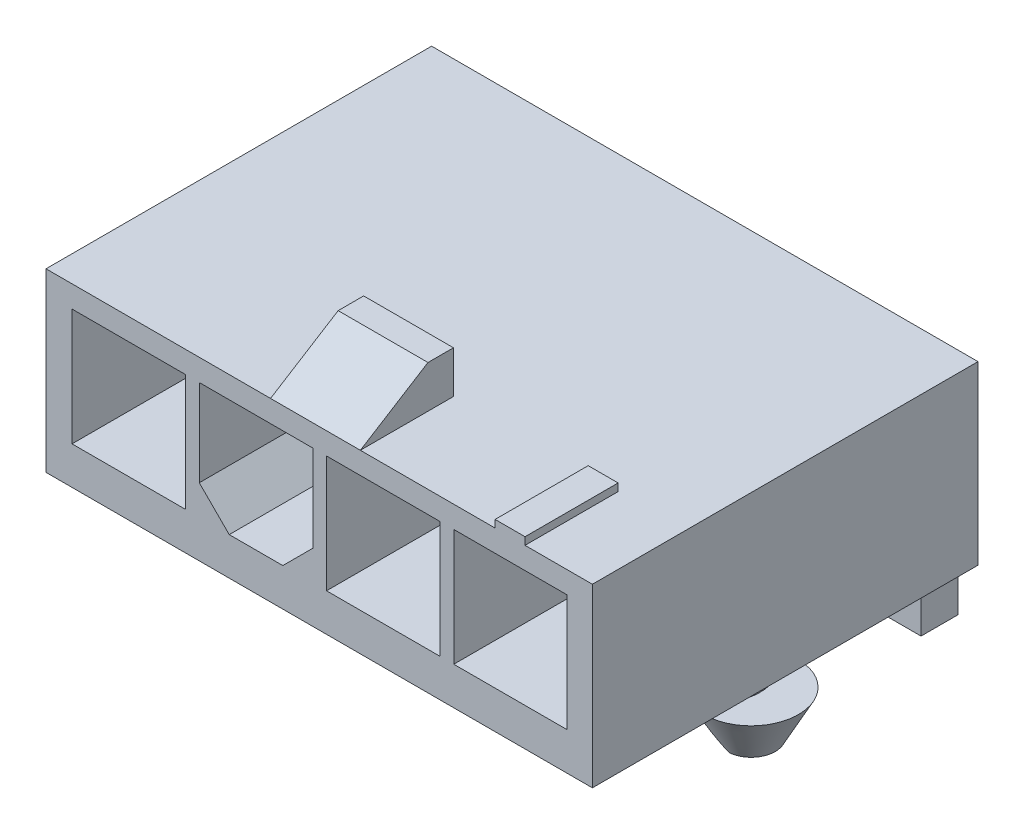
from build123d import *

# Parameters (mm, degrees)
SKETCH1_W                     = 18.25
SKETCH1_H                     = 12.88
BOSS_EXTRUDE1_DEPTH           = 5.89
SKETCH2_W                     = 3.79
SKETCH2_H                     = 3.9
CUT_EXTRUDE1_DEPTH            = 9
SKETCH3_W                     = 3
SKETCH3_H                     = 3.11
BOSS_EXTRUDE2_DEPTH           = 1.41
CUT_EXTRUDE2_DEPTH            = 3
SKETCH5_W                     = 1.23
SKETCH5_H                     = 1.23
CUT_EXTRUDE3_DEPTH            = 4
SKETCH8_W                     = 1.23
SKETCH8_H                     = 1.23
SKETCH9_W                     = 1
SKETCH9_H                     = 3.11
BOSS_EXTRUDE3_DEPTH           = 0.25
BOSS_EXTRUDE5_DEPTH           = 1.5875
BOSS_EXTRUDE6_DEPTH           = 1.46
BOSS_EXTRUDE6_DRAFT           = 28
BOSS_EXTRUDE6_PROFILE_2_DEPTH = 1.46
BOSS_EXTRUDE6_PROFILE_2_DRAFT = 28
BOSS_EXTRUDE6_PROFILE_3_DEPTH = 1.46
BOSS_EXTRUDE6_PROFILE_3_DRAFT = 28
BOSS_EXTRUDE6_PROFILE_4_DEPTH = 1.46
BOSS_EXTRUDE6_PROFILE_4_DRAFT = 28


with BuildPart() as part:
    # Sketch1 → Boss-Extrude1 (new body)
    with BuildSketch(Plane(origin=(0, 0, 0), x_dir=(1, 0, 0), z_dir=(0, 1, 0))):
        with Locations((9.125, 6.44)):
            Rectangle(SKETCH1_W, SKETCH1_H)
    extrude(amount=BOSS_EXTRUDE1_DEPTH)

    # Sketch2 → Cut-Extrude1 (cut)
    with BuildSketch(Plane.XY):
        with Locations((2.765, 3.21048567)):
            Rectangle(SKETCH2_W, SKETCH2_H)
        Polygon((5.12, 5.16048567), (8.91, 5.16048567), (8.91, 2.26048567), (7.91, 1.26048567), (6.12, 1.26048567), (5.12, 2.26048567), align=None)
        with Locations((11.265, 3.21048567)):
            Rectangle(SKETCH2_W, SKETCH2_H)
        with Locations((15.515, 3.21048567)):
            Rectangle(SKETCH2_W, SKETCH2_H)
    extrude(amount=-CUT_EXTRUDE1_DEPTH, mode=Mode.SUBTRACT)

    # Sketch3 → Boss-Extrude2 (add)
    with BuildSketch(Plane(origin=(0, 5.89, 0), x_dir=(1, 0, 0), z_dir=(0, 1, 0))):
        with Locations((9, 1.555)):
            Rectangle(SKETCH3_W, SKETCH3_H)
    extrude(amount=BOSS_EXTRUDE2_DEPTH)

    # Sketch4 → Cut-Extrude2 (cut)
    with BuildSketch(Plane.ZY.offset(-7.5)):
        Polygon((-2.258367839, 7.3), (0, 5.89), (0, 7.3), align=None)
    extrude(amount=-CUT_EXTRUDE2_DEPTH, mode=Mode.SUBTRACT)

    # Sketch5 → Cut-Extrude3 (cut)
    with BuildSketch(Plane(origin=(0, 0, -12.88), x_dir=(-1, 0, 0), z_dir=(0, 0, -1))):
        with Locations((-2.785, 2.645)):
            Rectangle(SKETCH5_W, SKETCH5_H)
        with Locations((-6.990239219, 2.642823938)):
            Rectangle(SKETCH5_W, SKETCH5_H)
        with Locations((-11.195478439, 2.640647876)):
            Rectangle(SKETCH5_W, SKETCH5_H)
        with Locations((-15.400717658, 2.638471814)):
            Rectangle(SKETCH5_W, SKETCH5_H)
    extrude(amount=-CUT_EXTRUDE3_DEPTH, mode=Mode.SUBTRACT)

    # Sweep2: sweep along a path in Sketch7
    with BuildLine(Plane.ZY) as sweep2_path:
        Line((-4.3, 2.72), (-12.700459496, 2.72))
        ThreePointArc((-12.700459496, 2.72), (-13.534520585, 2.374520585), (-13.88, 1.540459496))
        Line((-13.88, 1.540459496), (-13.88, -3.3375))
    # Sketch8 → Sweep2 (sweep)
    with BuildSketch(Plane.XZ.offset(3.3375)):
        with Locations((15.397064507, -13.830209109)):
            Rectangle(SKETCH8_W, SKETCH8_H)
        with Locations((11.191825288, -13.832385171)):
            Rectangle(SKETCH8_W, SKETCH8_H)
        with Locations((6.986586068, -13.834561233)):
            Rectangle(SKETCH8_W, SKETCH8_H)
        with Locations((2.781346849, -13.836737294)):
            Rectangle(SKETCH8_W, SKETCH8_H)
    sweep(path=sweep2_path.line)

    # Sketch9 → Boss-Extrude3 (add)
    with BuildSketch(Plane(origin=(0, 5.89, 0), x_dir=(1, 0, 0), z_dir=(0, 1, 0))):
        with Locations((15.5, 1.555)):
            Rectangle(SKETCH9_W, SKETCH9_H)
    extrude(amount=BOSS_EXTRUDE3_DEPTH)

    # Sketch10 → Boss-Extrude5 (add)
    with BuildSketch(Plane.XZ):
        with BuildLine():
            Line((2.55, -5.735786438), (2.55, -8.564213562))
            ThreePointArc((2.55, -8.564213562), (1.55, -7.15), (2.55, -5.735786438))
        make_face()
        with BuildLine():
            Line((3.55, -5.735786438), (3.55, -8.564213562))
            ThreePointArc((3.55, -8.564213562), (4.55, -7.15), (3.55, -5.735786438))
        make_face()
        with BuildLine():
            Line((14.7, -5.735786438), (14.7, -8.564213562))
            ThreePointArc((14.7, -8.564213562), (13.7, -7.15), (14.7, -5.735786438))
        make_face()
        with BuildLine():
            Line((15.7, -5.735786438), (15.7, -8.564213562))
            ThreePointArc((15.7, -8.564213562), (16.7, -7.15), (15.7, -5.735786438))
        make_face()
    extrude(amount=BOSS_EXTRUDE5_DEPTH)


with BuildPart() as boss_extrude6_tool:
    # Sketch12 → Boss-Extrude6 (with draft: the straight prism first)
    with BuildSketch(Plane.XZ.offset(1.5875)):
        with BuildLine():
            ThreePointArc((2.55, -5.735786438), (0.266263579, -7.15), (2.55, -8.564213562))
            Line((2.55, -8.564213562), (2.55, -5.735786438))
        make_face()
    extrude(amount=BOSS_EXTRUDE6_DEPTH)
    # Boss-Extrude6: the draft: its side faces are tilted about the plane it starts from
    boss_extrude6_sides = [boss_extrude6_tool.faces().sort_by_distance(p)[0] for p in [
        (2.55, -2.3175, -7.15),
        (0.266263579, -2.3175, -7.15),
    ]]
    draft(boss_extrude6_sides, Plane.XZ.offset(1.5875), BOSS_EXTRUDE6_DRAFT)


with BuildPart() as part_1:
    add(part.part)

    # Boss-Extrude6: add boss_extrude6_tool
    add(boss_extrude6_tool.part)


with BuildPart() as boss_extrude6_profile_2_tool:
    # Sketch12 → Boss-Extrude6 profile 2 (with draft: the straight prism first)
    with BuildSketch(Plane.XZ.offset(1.5875)):
        with BuildLine():
            Line((3.55, -5.735786438), (3.55, -8.564213562))
            ThreePointArc((3.55, -8.564213562), (5.833736421, -7.15), (3.55, -5.735786438))
        make_face()
    extrude(amount=BOSS_EXTRUDE6_PROFILE_2_DEPTH)
    # Boss-Extrude6 profile 2: the draft: its side faces are tilted about the plane it starts from
    boss_extrude6_profile_2_sides = [boss_extrude6_profile_2_tool.faces().sort_by_distance(p)[0] for p in [
        (3.55, -2.3175, -7.15),
        (5.833736421, -2.3175, -7.15),
    ]]
    draft(boss_extrude6_profile_2_sides, Plane.XZ.offset(1.5875), BOSS_EXTRUDE6_PROFILE_2_DRAFT)


with BuildPart() as part_2:
    add(part_1.part)

    # Boss-Extrude6 profile 2: add boss_extrude6_profile_2_tool
    add(boss_extrude6_profile_2_tool.part)


with BuildPart() as boss_extrude6_profile_3_tool:
    # Sketch12 → Boss-Extrude6 profile 3 (with draft: the straight prism first)
    with BuildSketch(Plane.XZ.offset(1.5875)):
        with BuildLine():
            ThreePointArc((14.7, -5.735786438), (12.416263579, -7.15), (14.7, -8.564213562))
            Line((14.7, -8.564213562), (14.7, -5.735786438))
        make_face()
    extrude(amount=BOSS_EXTRUDE6_PROFILE_3_DEPTH)
    # Boss-Extrude6 profile 3: the draft: its side faces are tilted about the plane it starts from
    boss_extrude6_profile_3_sides = [boss_extrude6_profile_3_tool.faces().sort_by_distance(p)[0] for p in [
        (12.416263579, -2.3175, -7.15),
        (14.7, -2.3175, -7.15),
    ]]
    draft(boss_extrude6_profile_3_sides, Plane.XZ.offset(1.5875), BOSS_EXTRUDE6_PROFILE_3_DRAFT)


with BuildPart() as part_3:
    add(part_2.part)

    # Boss-Extrude6 profile 3: add boss_extrude6_profile_3_tool
    add(boss_extrude6_profile_3_tool.part)


with BuildPart() as boss_extrude6_profile_4_tool:
    # Sketch12 → Boss-Extrude6 profile 4 (with draft: the straight prism first)
    with BuildSketch(Plane.XZ.offset(1.5875)):
        with BuildLine():
            Line((15.7, -5.735786438), (15.7, -8.564213562))
            ThreePointArc((15.7, -8.564213562), (17.983736421, -7.15), (15.7, -5.735786438))
        make_face()
    extrude(amount=BOSS_EXTRUDE6_PROFILE_4_DEPTH)
    # Boss-Extrude6 profile 4: the draft: its side faces are tilted about the plane it starts from
    boss_extrude6_profile_4_sides = [boss_extrude6_profile_4_tool.faces().sort_by_distance(p)[0] for p in [
        (15.7, -2.3175, -7.15),
        (17.983736421, -2.3175, -7.15),
    ]]
    draft(boss_extrude6_profile_4_sides, Plane.XZ.offset(1.5875), BOSS_EXTRUDE6_PROFILE_4_DRAFT)


with BuildPart() as part_4:
    add(part_3.part)

    # Boss-Extrude6 profile 4: add boss_extrude6_profile_4_tool
    add(boss_extrude6_profile_4_tool.part)


solid = part_4.part
